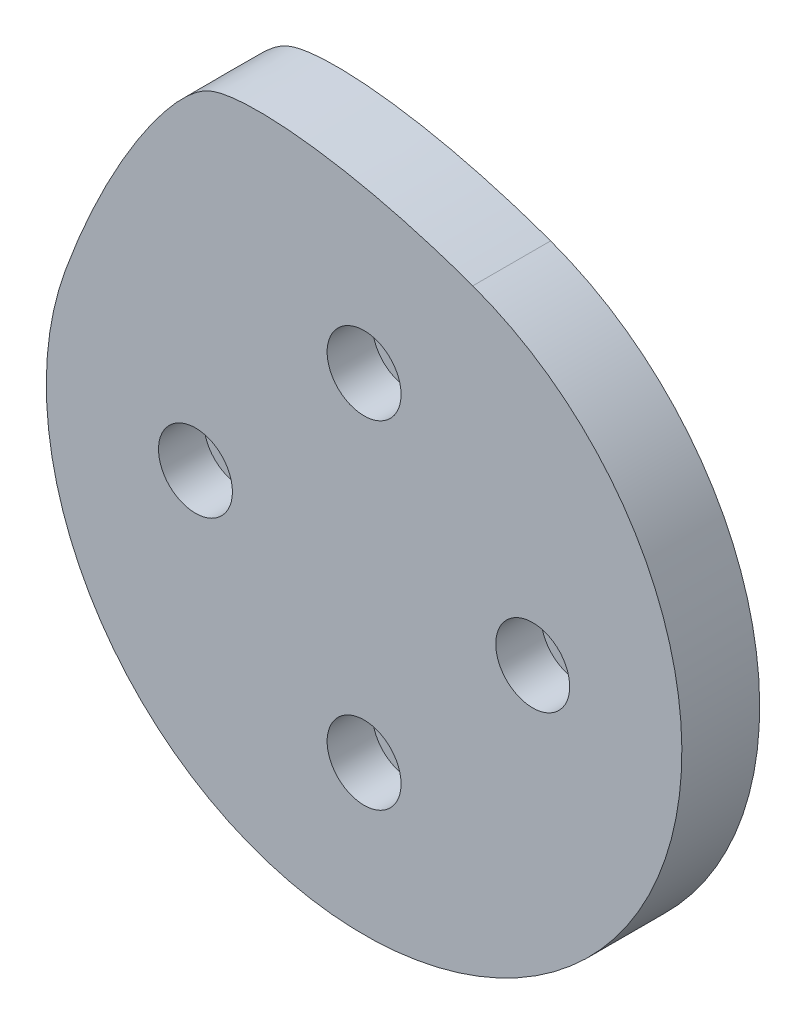
from build123d import *

# Parameters (mm, degrees)
SKETCH1_R           = 21
SKETCH1_R_2         = 2.85
BOSS_EXTRUDE1_DEPTH = 6
SKETCH2_R           = 24.5
SKETCH2_R_2         = 21
BOSS_EXTRUDE3_DEPTH = 6
SKETCH1_4_R         = 2.85
SKETCH1_4_R_2       = 1.6
BOSS_EXTRUDE2_DEPTH = 2.5
SKETCH3_R           = 21
SKETCH3_R_2         = 1.6
BOSS_EXTRUDE4_DEPTH = 0.5


with BuildPart() as part:
    # Sketch1 → Boss-Extrude1 (new body)
    with BuildSketch(Plane(origin=(0, 0, 0), x_dir=(0, 1, 0), z_dir=(0, 0, 1))):
        Circle(SKETCH1_R)
        with Locations((-13, 0)):
            Circle(SKETCH1_R_2, mode=Mode.SUBTRACT)
        with Locations((0, -13)):
            Circle(SKETCH1_R_2, mode=Mode.SUBTRACT)
        with Locations((13, 0)):
            Circle(SKETCH1_R_2, mode=Mode.SUBTRACT)
        with Locations((0, 13)):
            Circle(SKETCH1_R_2, mode=Mode.SUBTRACT)
    extrude(amount=BOSS_EXTRUDE1_DEPTH)

    # Sketch2 → Boss-Extrude3 (add)
    with BuildSketch(Plane(origin=(0, 0, 0), x_dir=(1, 0, 0), z_dir=(0, 0, -1))):
        Circle(SKETCH2_R)
        Circle(SKETCH2_R_2, mode=Mode.SUBTRACT)
        with BuildLine():
            ThreePointArc((8.379493511, -23.022469209), (-10.354147413, -22.204540782), (-23.022469209, -8.379493511))
            add(Edge.make_bspline(
                [(-23.022469209, -8.379493511), (-19.944287919, -16.836727099), (-14.723681196, -24.624750138), (-9.399453165, -27.107478442), (-0.077740076, -26.100650499), (8.379493511, -23.022469209)],
                knots=[0, 0, 0, 0, 0.45, 0.55, 1, 1, 1, 1], degree=3))
        make_face()
    extrude(amount=-BOSS_EXTRUDE3_DEPTH)

    # Sketch1_4 → Boss-Extrude2 (add)
    with BuildSketch(Plane(origin=(0, 0, 0), x_dir=(0, 1, 0), z_dir=(0, 0, 1))):
        with Locations((-13, 0)):
            Circle(SKETCH1_4_R)
        with Locations((-13, 0)):
            Circle(SKETCH1_4_R_2, mode=Mode.SUBTRACT)
        with Locations((0, 13)):
            Circle(SKETCH1_4_R)
        with Locations((0, 13)):
            Circle(SKETCH1_4_R_2, mode=Mode.SUBTRACT)
        with Locations((13, 0)):
            Circle(SKETCH1_4_R)
        with Locations((13, 0)):
            Circle(SKETCH1_4_R_2, mode=Mode.SUBTRACT)
        with Locations((0, -13)):
            Circle(SKETCH1_4_R)
        with Locations((0, -13)):
            Circle(SKETCH1_4_R_2, mode=Mode.SUBTRACT)
    extrude(amount=BOSS_EXTRUDE2_DEPTH)

    # Sketch3 → Boss-Extrude4 (add)
    with BuildSketch(Plane(origin=(0, 0, 0), x_dir=(1, 0, 0), z_dir=(0, 0, -1))):
        Circle(SKETCH3_R)
        with Locations((13, 0)):
            Circle(SKETCH3_R_2, mode=Mode.SUBTRACT)
        with Locations((0, 13)):
            Circle(SKETCH3_R_2, mode=Mode.SUBTRACT)
        with Locations((-13, 0)):
            Circle(SKETCH3_R_2, mode=Mode.SUBTRACT)
        with Locations((0, -13)):
            Circle(SKETCH3_R_2, mode=Mode.SUBTRACT)
    extrude(amount=BOSS_EXTRUDE4_DEPTH)


solid = part.part
